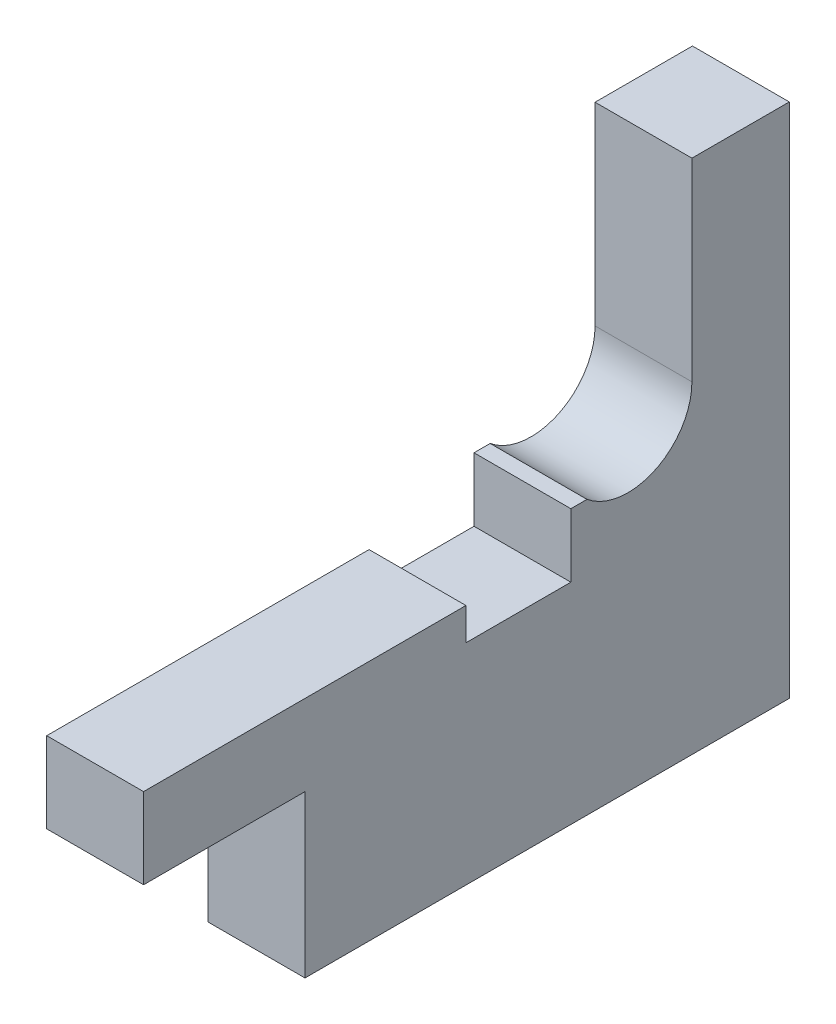
from build123d import *

# Parameters (mm, degrees)
BOSS_EXTRUDE1_DEPTH = 6


with BuildPart() as part:
    # Sketch1 → Boss-Extrude1 (new body)
    with BuildSketch(Plane(origin=(0, 0, 0), x_dir=(0, 0, -1), z_dir=(1, 0, 0))):
        with BuildLine():
            Line((3.96875, 0), (3.96875, 12))
            Line((3.96875, 12), (10, 12))
            Line((10, 12), (10, -20))
            Line((10, -20), (-20, -20))
            Line((-20, -20), (-20, -10))
            Line((-20, -10), (-30, -10))
            Line((-30, -10), (-30, -5))
            Line((-30, -5), (-10.03125, -5))
            Line((-10.03125, -5), (-10.03125, -7))
            Line((-10.03125, -7), (-3.53125, -7))
            Line((-3.53125, -7), (-3.53125, -3.056754815))
            Line((-3.53125, -3.056754815), (-2.53125, -3.056754815))
            ThreePointArc((-2.53125, -3.056754815), (1.68894614, -3.591439475), (3.96875, 0))
        make_face()
    extrude(amount=BOSS_EXTRUDE1_DEPTH)


solid = part.part
